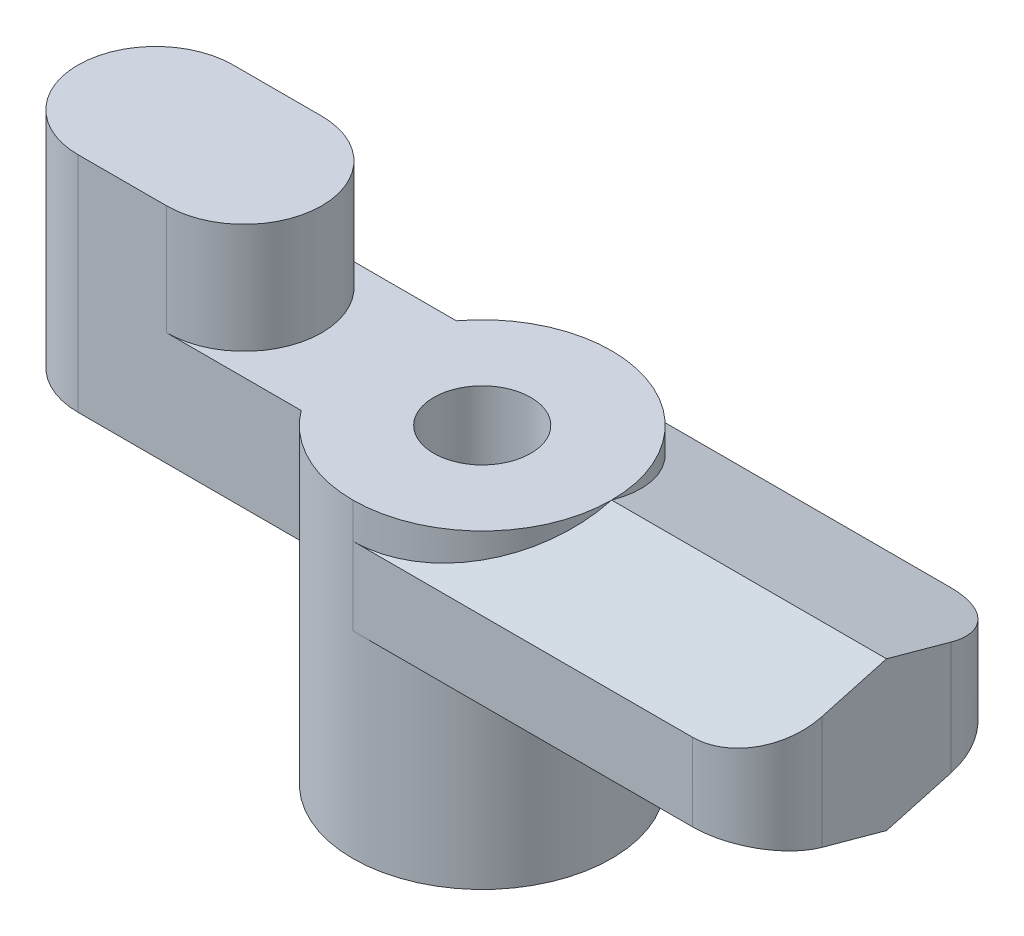
from build123d import *

# Parameters (mm, degrees)
SKETCH1_R           = 6.35
BOSS_EXTRUDE1_DEPTH = 15.24
BOSS_EXTRUDE2_DEPTH = 19.84375
FILLET1_R           = 3.175
SKETCH3_R           = 2.38125
CUT_EXTRUDE1_DEPTH  = 26.813843458
BOSS_EXTRUDE3_DEPTH = 5.55625
BOSS_EXTRUDE4_DEPTH = 5.3975


with BuildPart() as part:
    # Sketch1 → Boss-Extrude1 (new body)
    with BuildSketch(Plane(origin=(0, 0, 0), x_dir=(1, 0, 0), z_dir=(0, 1, 0))):
        with Locations(Location((0, 0, 0), (0, 0, 90))):
            Circle(SKETCH1_R)
    extrude(amount=BOSS_EXTRUDE1_DEPTH)

    # Sketch2 → Boss-Extrude2 (add)
    with BuildSketch(Plane(origin=(0, 0, 0), x_dir=(0, 0, -1), z_dir=(1, 0, 0))):
        Polygon((-6.35, 9.68375), (-6.35, 13.49375), (0, 15.24), (6.35, 13.49375), (6.35, 9.68375), (0, 7.9375), align=None)
    extrude(amount=BOSS_EXTRUDE2_DEPTH)

    # Fillet1
    fillet1_edges = [part.edges().sort_by_distance(p)[0] for p in [
        (19.84375, 11.58875, 6.35),
        (19.84375, 11.58875, -6.35),
    ]]
    fillet(fillet1_edges, radius=FILLET1_R)

    # Sketch3 → Cut-Extrude1 (cut, through all)
    with BuildSketch(Plane.XZ):
        with Locations(Location((0, 0, 0), (0, 0, 270))):
            Circle(SKETCH3_R)
    extrude(amount=-CUT_EXTRUDE1_DEPTH, mode=Mode.SUBTRACT)

    # Sketch4 → Boss-Extrude3 (add)
    with BuildSketch(Plane(origin=(0, 15.24, 0), x_dir=(1, 0, 0), z_dir=(0, 1, 0))):
        with BuildLine():
            Line((-5.08, -3.81), (-16.03375, -3.81))
            ThreePointArc((-16.03375, -3.81), (-19.84375, 0), (-16.03375, 3.81))
            Line((-16.03375, 3.81), (-5.08, 3.81))
            ThreePointArc((-5.08, 3.81), (-6.35, 0), (-5.08, -3.81))
        make_face()
    extrude(amount=-BOSS_EXTRUDE3_DEPTH)

    # Sketch5 → Boss-Extrude4 (add)
    with BuildSketch(Plane(origin=(0, 15.24, 0), x_dir=(1, 0, 0), z_dir=(0, 1, 0))):
        with BuildLine():
            Line((-16.03375, 3.81), (-11.684, 3.81))
            ThreePointArc((-11.684, 3.81), (-7.874, 0), (-11.684, -3.81))
            Line((-11.684, -3.81), (-16.03375, -3.81))
            ThreePointArc((-16.03375, -3.81), (-19.84375, 0), (-16.03375, 3.81))
        make_face()
    extrude(amount=BOSS_EXTRUDE4_DEPTH)


solid = part.part
